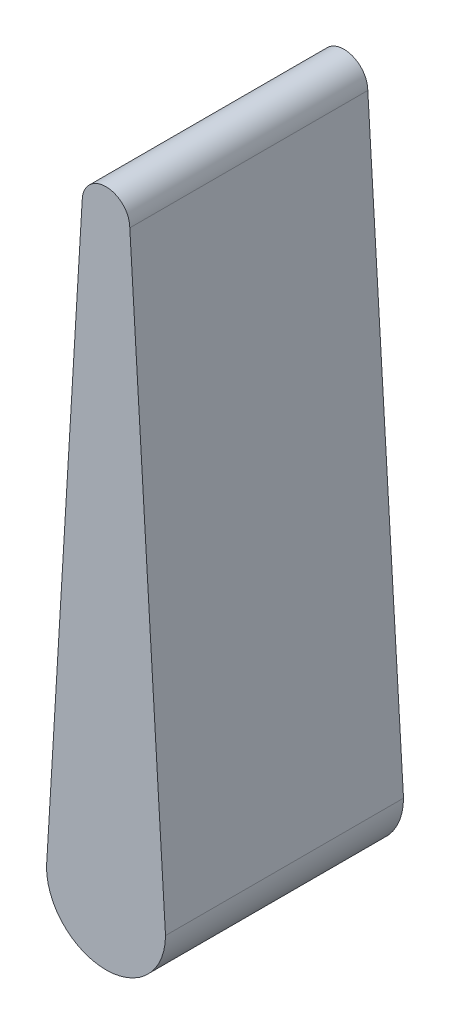
from build123d import *

# Parameters (mm, degrees)
BOSS_EXTRUDE1_DEPTH = 6.35


with BuildPart() as part:
    # Sketch1 → Boss-Extrude1 (new body, symmetric)
    with BuildSketch(Plane.XY):
        with BuildLine():
            Line((1.27, 31.75), (3.175, 0))
            ThreePointArc((3.175, 0), (0, -3.175), (-3.175, 0))
            Line((-3.175, 0), (-1.27, 31.75))
            ThreePointArc((-1.27, 31.75), (0, 33.02), (1.27, 31.75))
        make_face()
    extrude(amount=BOSS_EXTRUDE1_DEPTH, both=True)


solid = part.part
